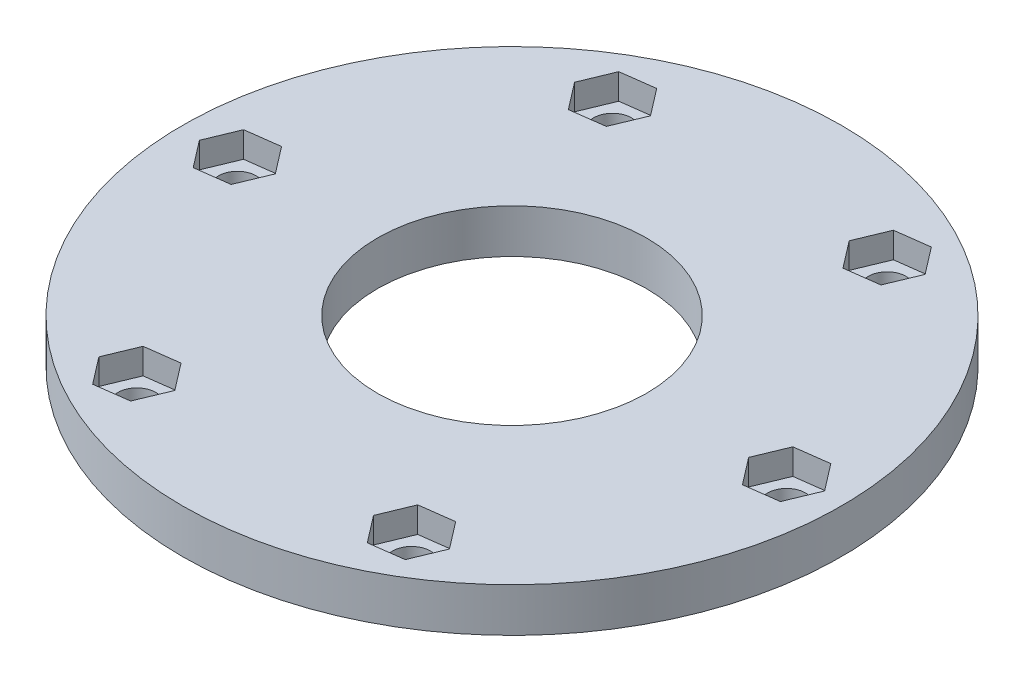
from build123d import *

# Parameters (mm, degrees)
SKETCH2_R           = 45
SKETCH2_R_2         = 18.375
BOSS_EXTRUDE1_DEPTH = 6
SKETCH2_3_R         = 2.575
CUT_EXTRUDE1_DEPTH  = 7
CUT_EXTRUDE3_START  = 6
CUT_EXTRUDE3_DEPTH  = 3.5


with BuildPart() as part:
    # Sketch2 → Boss-Extrude1 (new body)
    with BuildSketch(Plane(origin=(0, 0, 0), x_dir=(1, 0, 0), z_dir=(0, 1, 0))):
        with Locations((0.5741705, -1.235944224)):
            Circle(SKETCH2_R)
        with Locations((0.5741705, -1.235944224)):
            Circle(SKETCH2_R_2, mode=Mode.SUBTRACT)
    extrude(amount=BOSS_EXTRUDE1_DEPTH)

    # Sketch2_3 → Cut-Extrude1 (cut, through all)
    with BuildSketch(Plane(origin=(0, 0, 0), x_dir=(1, 0, 0), z_dir=(0, 1, 0))):
        with Locations((-18.1758295, 31.240008418)):
            Circle(SKETCH2_3_R)
        with Locations((19.3241705, 31.240008418)):
            Circle(SKETCH2_3_R)
        with Locations((38.0741705, -1.235944224)):
            Circle(SKETCH2_3_R)
        with Locations((19.3241705, -33.711896866)):
            Circle(SKETCH2_3_R)
        with Locations((-18.1758295, -33.711896866)):
            Circle(SKETCH2_3_R)
        with Locations((-36.9258295, -1.235944224)):
            Circle(SKETCH2_3_R)
    extrude(amount=CUT_EXTRUDE1_DEPTH, mode=Mode.SUBTRACT)

    # Sketch2_5 → Cut-Extrude3 (cut)
    with BuildSketch(Plane(origin=(0, 0, 0), x_dir=(1, 0, 0), z_dir=(0, 1, 0)).offset(CUT_EXTRUDE3_START)):
        Polygon((22.138316387, 27.577507051), (23.903062668, 31.845879563), (21.088916781, 35.508380929), (16.510024613, 34.902509784), (14.745278332, 30.634137273), (17.559424219, 26.971635906), align=None)
        Polygon((-15.361683613, 27.577507051), (-13.596937332, 31.845879563), (-16.411083219, 35.508380929), (-20.989975387, 34.902509784), (-22.754721668, 30.634137273), (-19.940575781, 26.971635906), align=None)
        Polygon((36.309424219, -5.504316736), (40.888316387, -4.898445591), (42.653062668, -0.630073079), (39.838916781, 3.032428287), (35.260024613, 2.426557142), (33.495278332, -1.841815369), align=None)
        Polygon((14.745278332, -34.317768011), (17.559424219, -37.980269378), (22.138316387, -37.374398233), (23.903062668, -33.106025721), (21.088916781, -29.443524355), (16.510024613, -30.0493955), align=None)
        Polygon((-20.989975387, -30.0493955), (-22.754721668, -34.317768011), (-19.940575781, -37.980269378), (-15.361683613, -37.374398233), (-13.596937332, -33.106025721), (-16.411083219, -29.443524355), align=None)
        Polygon((-35.161083219, 3.032428287), (-39.739975387, 2.426557142), (-41.504721668, -1.841815369), (-38.690575781, -5.504316736), (-34.111683613, -4.898445591), (-32.346937332, -0.630073079), align=None)
    extrude(amount=-CUT_EXTRUDE3_DEPTH, mode=Mode.SUBTRACT)


solid = part.part
